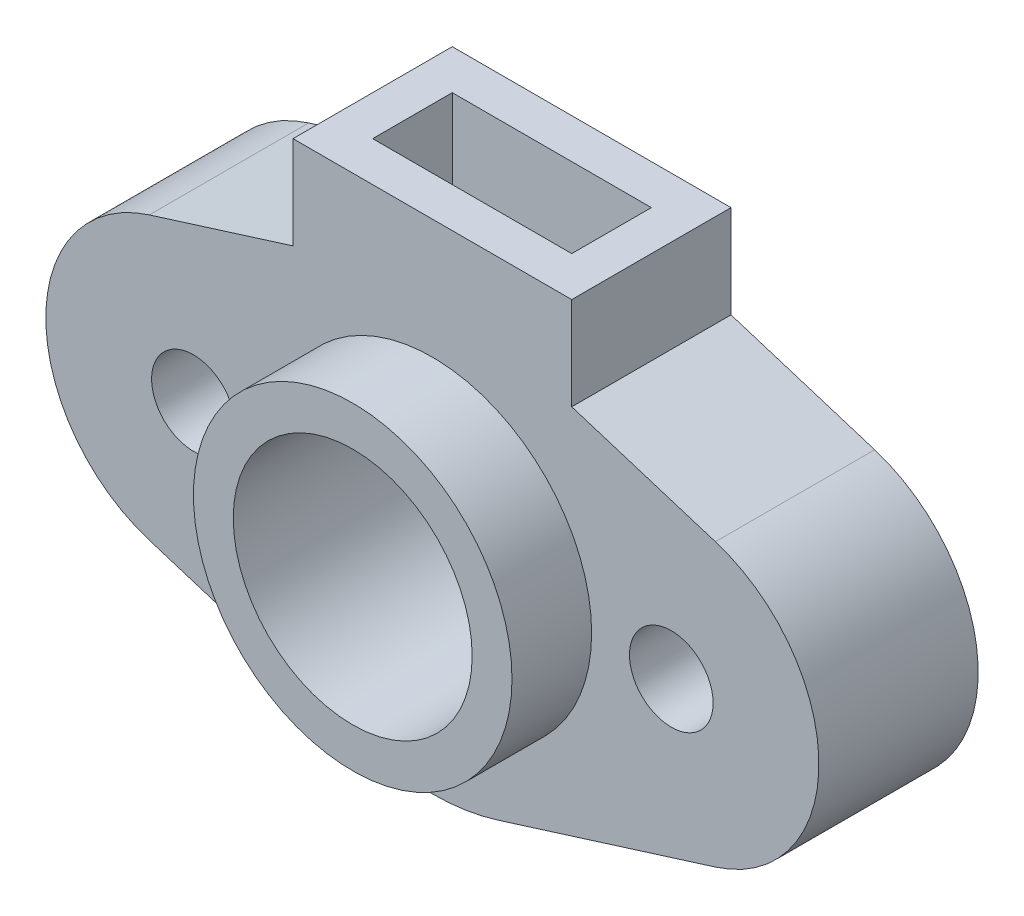
from build123d import *

# Parameters (mm, degrees)
IZIM1_R                     = 10.5
IZIM1_R_2                   = 40
IZIM1_R_3                   = 30
Y_KSEKLIK_EKSTR_ZYON1_DEPTH = 20
IZIM3_R                     = 40
IZIM3_R_2                   = 30
Y_KSEKLIK_EKSTR_ZYON2_DEPTH = 20
IZIM4_W                     = 70
IZIM4_H                     = 40
Y_KSEKLIK_EKSTR_ZYON3_DEPTH = 40
IZIM6_W                     = 50
IZIM6_H                     = 20
KES_EKSTR_ZYON4_DEPTH       = 30
IZIM8_R                     = 5
KES_EKSTR_ZYON5_DEPTH       = 96


with BuildPart() as part:
    # Çizim1 → Yükseklik-Ekstrüzyon1 (new body, symmetric)
    with BuildSketch(Plane.XY):
        with BuildLine():
            Line((-71.077917778, -35.375500425), (-16.436310678, -52.48664298))
            ThreePointArc((-16.436310678, -52.48664298), (0, -55), (16.436310678, -52.48664298))
            Line((16.436310678, -52.48664298), (71.077917778, -35.375500425))
            ThreePointArc((71.077917778, -35.375500425), (97.06947926, 0), (71.077917778, 35.375500425))
            Line((71.077917778, 35.375500425), (16.436310678, 52.48664298))
            ThreePointArc((16.436310678, 52.48664298), (0, 55), (-16.436310678, 52.48664298))
            Line((-16.436310678, 52.48664298), (-71.077917778, 35.375500425))
            ThreePointArc((-71.077917778, 35.375500425), (-97.06947926, 0), (-71.077917778, -35.375500425))
        make_face()
        with Locations((-60, 0)):
            Circle(IZIM1_R, mode=Mode.SUBTRACT)
        with Locations((60, 0)):
            Circle(IZIM1_R, mode=Mode.SUBTRACT)
        Circle(IZIM1_R_2, mode=Mode.SUBTRACT)
        Circle(IZIM1_R_2)
        Circle(IZIM1_R_3, mode=Mode.SUBTRACT)
    extrude(amount=Y_KSEKLIK_EKSTR_ZYON1_DEPTH, both=True)

    # Çizim3 → Yükseklik-Ekstrüzyon2 (add)
    with BuildSketch(Plane.XY.offset(20)):
        Circle(IZIM3_R)
        Circle(IZIM3_R_2, mode=Mode.SUBTRACT)
    extrude(amount=Y_KSEKLIK_EKSTR_ZYON2_DEPTH)

    # Çizim4 → Yükseklik-Ekstrüzyon3 (add)
    with BuildSketch(Plane.XY.offset(20)):
        with Locations((0, 50)):
            Rectangle(IZIM4_W, IZIM4_H)
    extrude(amount=-Y_KSEKLIK_EKSTR_ZYON3_DEPTH)

    # Çizim6 → Kes-Ekstrüzyon4 (cut)
    with BuildSketch(Plane(origin=(0, 70, 0), x_dir=(1, 0, 0), z_dir=(0, 1, 0))):
        Rectangle(IZIM6_W, IZIM6_H)
    extrude(amount=-KES_EKSTR_ZYON4_DEPTH, mode=Mode.SUBTRACT)

    # Çizim8 → Kes-Ekstrüzyon5 (cut, through all)
    with BuildSketch(Plane(origin=(0, 40, 0), x_dir=(1, 0, 0), z_dir=(0, 1, 0))):
        Circle(IZIM8_R)
    extrude(amount=-KES_EKSTR_ZYON5_DEPTH, mode=Mode.SUBTRACT)


solid = part.part
